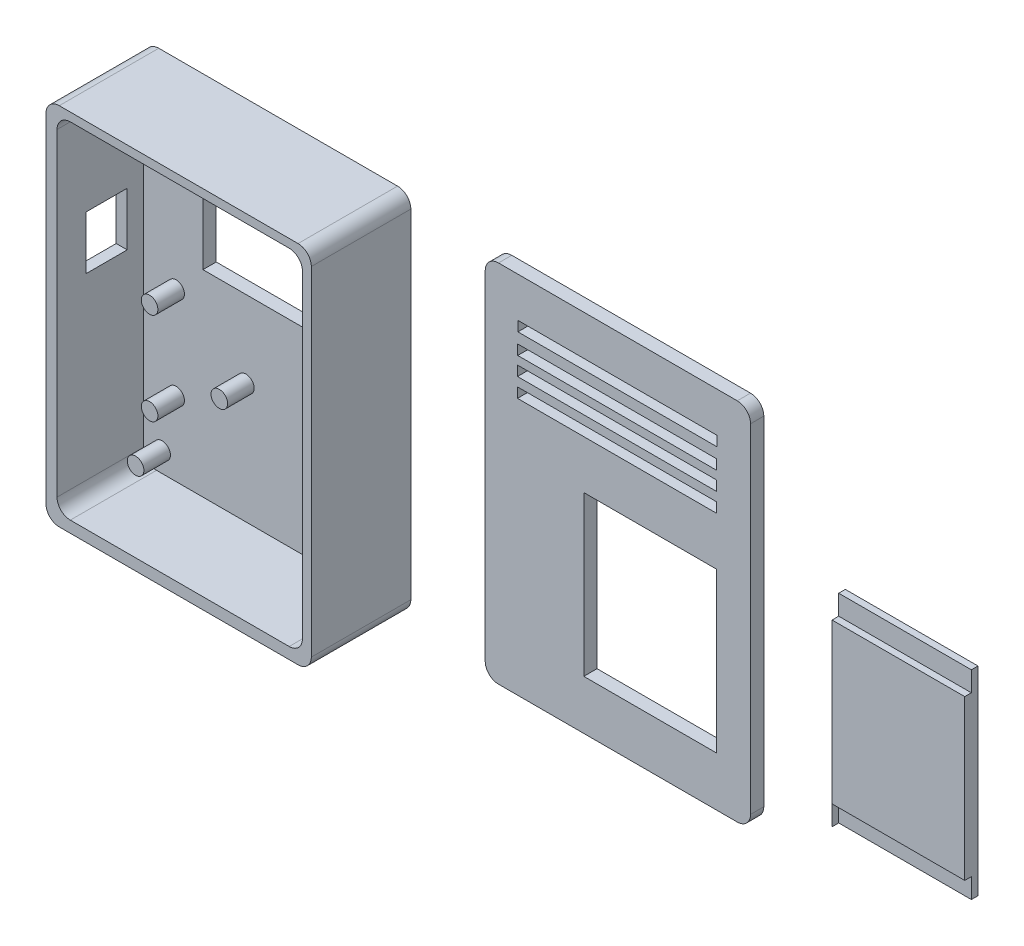
from build123d import *

# Parameters (mm, degrees)
BOSS_EXTRUDE1_DEPTH     = 30
BOSS_EXTRUDE1_2_DEPTH   = 30
CUT_EXTRUDE1_DEPTH      = 30
CUT_EXTRUDE1_DEPTH_BACK = 30
SKETCH2_W               = 35.5
SKETCH2_H               = 33.7
CUT_EXTRUDE3_DEPTH      = 26
SKETCH6_R               = 2.5
BOSS_EXTRUDE4_DEPTH     = 8
SKETCH7_W               = 40
SKETCH7_H               = 40
CUT_EXTRUDE4_DEPTH      = 2
SKETCH8_W               = 3
SKETCH8_H               = 16
CUT_EXTRUDE6_DEPTH      = 10
SKETCH9_R               = 6
CUT_EXTRUDE7_DEPTH      = 10
SKETCH10_W              = 12.5
SKETCH10_H              = 16.1
CUT_EXTRUDE8_DEPTH      = 10
SKETCH11_W              = 95.321687865
SKETCH11_H              = 120.330039434
CUT_EXTRUDE9_DEPTH      = 26
SKETCH12_W              = 60
SKETCH12_H              = 3
CUT_EXTRUDE10_DEPTH     = 10
SKETCH13_W              = 40
SKETCH13_H              = 48
CUT_EXTRUDE11_DEPTH     = 10
SKETCH14_W              = 40
SKETCH14_H              = 60
BOSS_EXTRUDE5_DEPTH     = 4
SKETCH15_W              = 40
SKETCH15_H              = 6
CUT_EXTRUDE12_DEPTH     = 2
SKETCH16_W              = 40
SKETCH16_H              = 6
CUT_EXTRUDE16_DEPTH     = 2


with BuildPart() as part:
    # Sketch1 → Boss-Extrude1 (new body)
    with BuildSketch(Plane.XY):
        with BuildLine():
            Line((20.974483597, 66.715066829), (92.974483597, 66.715066829))
            ThreePointArc((92.974483597, 66.715066829), (95.802910721, 65.543493953), (96.974483597, 62.715066829))
            Line((96.974483597, 62.715066829), (96.974483597, -39.284933171))
            ThreePointArc((96.974483597, -39.284933171), (95.802910721, -42.113360296), (92.974483597, -43.284933171))
            Line((92.974483597, -43.284933171), (20.974483597, -43.284933171))
            ThreePointArc((20.974483597, -43.284933171), (18.146056472, -42.113360296), (16.974483597, -39.284933171))
            Line((16.974483597, -39.284933171), (16.974483597, 62.715066829))
            ThreePointArc((16.974483597, 62.715066829), (18.146056472, 65.543493953), (20.974483597, 66.715066829))
        make_face()
    extrude(amount=BOSS_EXTRUDE1_DEPTH)


with BuildPart() as body_2:
    # Sketch1 → Boss-Extrude1 2 (new body)
    with BuildSketch(Plane.XY):
        with BuildLine():
            Line((-85.455528554, 67.563791009), (-13.455528554, 67.563791009))
            ThreePointArc((-13.455528554, 67.563791009), (-10.627101429, 66.392218133), (-9.455528554, 63.563791009))
            Line((-9.455528554, 63.563791009), (-9.455528554, -38.436208991))
            ThreePointArc((-9.455528554, -38.436208991), (-10.627101429, -41.264636116), (-13.455528554, -42.436208991))
            Line((-13.455528554, -42.436208991), (-85.455528554, -42.436208991))
            ThreePointArc((-85.455528554, -42.436208991), (-88.283955679, -41.264636116), (-89.455528554, -38.436208991))
            Line((-89.455528554, -38.436208991), (-89.455528554, 63.563791009))
            ThreePointArc((-89.455528554, 63.563791009), (-88.283955679, 66.392218133), (-85.455528554, 67.563791009))
        make_face()
    extrude(amount=BOSS_EXTRUDE1_2_DEPTH)

    # Sketch2 → Cut-Extrude1 (cut, two sides: drawn at the far end of the back side and taken through both)
    with BuildSketch(Plane.XY.offset(30).offset(-CUT_EXTRUDE1_DEPTH_BACK)):
        with Locations((-50.386245778, 37.25801999)):
            Rectangle(SKETCH2_W, SKETCH2_H)
    extrude(amount=CUT_EXTRUDE1_DEPTH + CUT_EXTRUDE1_DEPTH_BACK, mode=Mode.SUBTRACT)


with BuildPart() as cut_extrude3_tool:
    # Sketch4 → Cut-Extrude3 (new body)
    with BuildSketch(Plane.XY.offset(30)):
        with BuildLine():
            Line((23.91157104, 63.897821022), (89.91157104, 63.897821022))
            ThreePointArc((89.91157104, 63.897821022), (92.739998164, 62.726248147), (93.91157104, 59.897821022))
            Line((93.91157104, 59.897821022), (93.91157104, -36.102178978))
            ThreePointArc((93.91157104, -36.102178978), (92.739998164, -38.930606103), (89.91157104, -40.102178978))
            Line((89.91157104, -40.102178978), (23.91157104, -40.102178978))
            ThreePointArc((23.91157104, -40.102178978), (21.083143915, -38.930606103), (19.91157104, -36.102178978))
            Line((19.91157104, -36.102178978), (19.91157104, 59.897821022))
            ThreePointArc((19.91157104, 59.897821022), (21.083143915, 62.726248147), (23.91157104, 63.897821022))
        make_face()
        with BuildLine():
            Line((-82.132362374, 65.007321048), (-16.132362374, 65.007321048))
            ThreePointArc((-16.132362374, 65.007321048), (-13.303935249, 63.835748173), (-12.132362374, 61.007321048))
            Line((-12.132362374, 61.007321048), (-12.132362374, -34.992678952))
            ThreePointArc((-12.132362374, -34.992678952), (-13.303935249, -37.821106077), (-16.132362374, -38.992678952))
            Line((-16.132362374, -38.992678952), (-82.132362374, -38.992678952))
            ThreePointArc((-82.132362374, -38.992678952), (-84.960789499, -37.821106077), (-86.132362374, -34.992678952))
            Line((-86.132362374, -34.992678952), (-86.132362374, 61.007321048))
            ThreePointArc((-86.132362374, 61.007321048), (-84.960789499, 63.835748173), (-82.132362374, 65.007321048))
        make_face()
    extrude(amount=-CUT_EXTRUDE3_DEPTH)


with BuildPart() as part_1:
    add(part.part)

    # Cut-Extrude3: cut by cut_extrude3_tool
    add(cut_extrude3_tool.part, mode=Mode.SUBTRACT)

    # Sketch11 → Cut-Extrude9 (cut)
    with BuildSketch(Plane.XY.offset(30)):
        with Locations((57.581799377, 11.372053132)):
            Rectangle(SKETCH11_W, SKETCH11_H)
    extrude(amount=-CUT_EXTRUDE9_DEPTH, mode=Mode.SUBTRACT)

    # Sketch12 → Cut-Extrude10 (cut)
    with BuildSketch(Plane(origin=(0, 0, 0), x_dir=(-1, 0, 0), z_dir=(0, 0, -1))):
        with Locations((-56.77947587, 46.957115984)):
            Rectangle(SKETCH12_W, SKETCH12_H)
        with Locations((-56.829034644, 53.146498435)):
            Rectangle(SKETCH12_W, SKETCH12_H)
        with Locations((-56.705135858, 41.423213074)):
            Rectangle(SKETCH12_W, SKETCH12_H)
        with Locations((-56.705135858, 35.718618338)):
            Rectangle(SKETCH12_W, SKETCH12_H)
    extrude(amount=-CUT_EXTRUDE10_DEPTH, mode=Mode.SUBTRACT)

    # Sketch13 → Cut-Extrude11 (cut)
    with BuildSketch(Plane(origin=(0, 0, 0), x_dir=(-1, 0, 0), z_dir=(0, 0, -1))):
        with Locations((-66.695382207, -4.37674857)):
            Rectangle(SKETCH13_W, SKETCH13_H)
    extrude(amount=-CUT_EXTRUDE11_DEPTH, mode=Mode.SUBTRACT)

    # Sketch15 → Cut-Extrude12 (cut)
    with BuildSketch(Plane(origin=(0, 0, 0), x_dir=(-1, 0, 0), z_dir=(0, 0, -1))):
        with Locations((-66.699810311, 22.62325143)):
            Rectangle(SKETCH15_W, SKETCH15_H)
        with Locations((-66.680744565, -31.383516818)):
            Rectangle(SKETCH15_W, SKETCH15_H)
    extrude(amount=-CUT_EXTRUDE12_DEPTH, mode=Mode.SUBTRACT)


with BuildPart() as body_2_1:
    add(body_2.part)

    # Cut-Extrude3: cut by cut_extrude3_tool
    add(cut_extrude3_tool.part, mode=Mode.SUBTRACT)

    # Sketch6 → Boss-Extrude4 (add)
    with BuildSketch(Plane.XY.offset(4)):
        with Locations((-80.439971439, 58.969820131)):
            Circle(SKETCH6_R)
        with Locations((-80.439971439, -32.933759837)):
            Circle(SKETCH6_R)
        with Locations((-19.080816578, 58.429210837)):
            Circle(SKETCH6_R)
        with Locations((-19.080816578, -32.933759837)):
            Circle(SKETCH6_R)
        with Locations((-76.2182608, -16.589165255)):
            Circle(SKETCH6_R)
        with Locations((-76.2182608, 11.204722955)):
            Circle(SKETCH6_R)
        with Locations((-55.194678693, -2.8703871)):
            Circle(SKETCH6_R)
    extrude(amount=BOSS_EXTRUDE4_DEPTH)

    # Sketch7 → Cut-Extrude4 (cut)
    with BuildSketch(Plane(origin=(0, 0, 0), x_dir=(-1, 0, 0), z_dir=(0, 0, -1))):
        with Locations((50.037991375, -4.23667758)):
            Rectangle(SKETCH7_W, SKETCH7_H)
    extrude(amount=-CUT_EXTRUDE4_DEPTH, mode=Mode.SUBTRACT)

    # Sketch8 → Cut-Extrude6 (cut)
    with BuildSketch(Plane(origin=(0, 0, 2), x_dir=(-1, 0, 0), z_dir=(0, 0, -1))):
        with Locations((32.817132527, -14.820749727)):
            Rectangle(SKETCH8_W, SKETCH8_H)
    extrude(amount=-CUT_EXTRUDE6_DEPTH, mode=Mode.SUBTRACT)

    # Sketch9 → Cut-Extrude7 (cut)
    with BuildSketch(Plane(origin=(0, 0, 0), x_dir=(-1, 0, 0), z_dir=(0, 0, -1))):
        with Locations((20.403181, -14.917714738)):
            Circle(SKETCH9_R)
    extrude(amount=-CUT_EXTRUDE7_DEPTH, mode=Mode.SUBTRACT)

    # Sketch10 → Cut-Extrude8 (cut)
    with BuildSketch(Plane.ZY.offset(89.455528554)):
        with Locations((15.082452047, 27.039311298)):
            Rectangle(SKETCH10_W, SKETCH10_H)
    extrude(amount=-CUT_EXTRUDE8_DEPTH, mode=Mode.SUBTRACT)


with BuildPart() as body_3:
    # Sketch14 → Boss-Extrude5 (new body)
    with BuildSketch(Plane(origin=(3.927933069, 1.340530515, 0), x_dir=(-1, 0, 0), z_dir=(0, 0, -1))):
        with Locations((-133.631501649, -5.574519781)):
            Rectangle(SKETCH14_W, SKETCH14_H)
    extrude(amount=BOSS_EXTRUDE5_DEPTH)

    # Sketch16 → Cut-Extrude16 (cut)
    with BuildSketch(Plane.XY):
        with Locations((137.559434718, 22.766010733)):
            Rectangle(SKETCH16_W, SKETCH16_H)
        with Locations((137.560044489, -31.236499994)):
            Rectangle(SKETCH16_W, SKETCH16_H)
    extrude(amount=-CUT_EXTRUDE16_DEPTH, mode=Mode.SUBTRACT)


solid = Compound([part_1.part, body_2_1.part, body_3.part])
